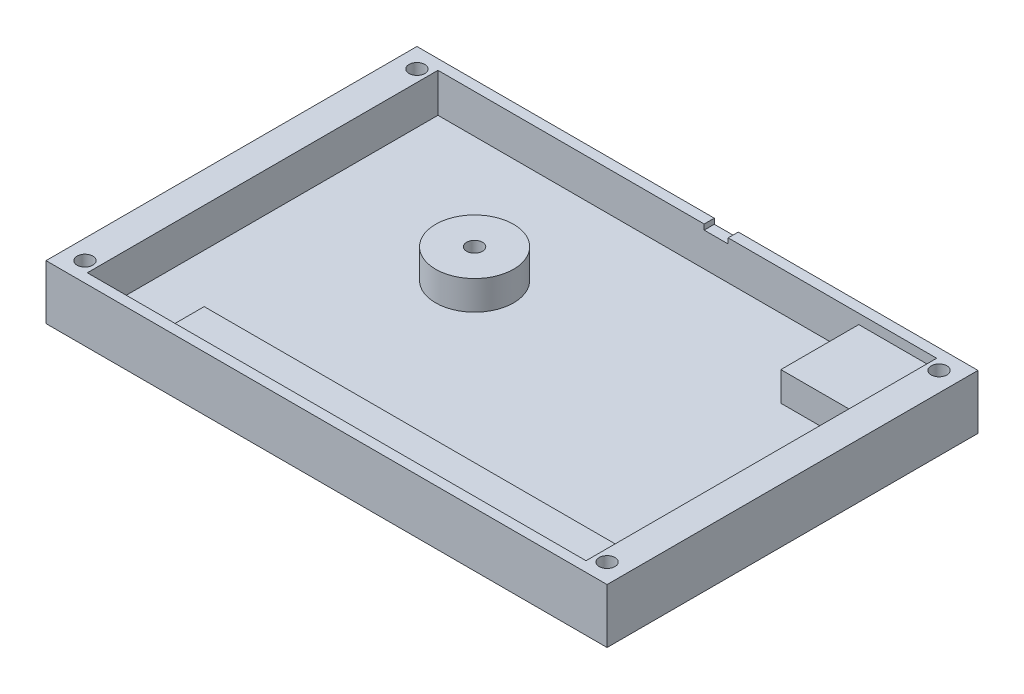
from build123d import *

# Parameters (mm, degrees)
SKETCH1_W           = 91.44
SKETCH1_H           = 60.452
BOSS_EXTRUDE1_DEPTH = 8.89
SKETCH2_W           = 81.28
SKETCH2_H           = 57.15
CUT_EXTRUDE1_DEPTH  = 1.6002
SKETCH3_R           = 6.35
SKETCH3_R_2         = 1.28905
CUT_EXTRUDE2_DEPTH  = 4.7498
SKETCH4_R           = 1.28905
CUT_EXTRUDE3_DEPTH  = 56.524423239
CUT_EXTRUDE4_REACH  = 78.314
SKETCH5_W           = 3.9116
SKETCH5_H           = 0.8636


with BuildPart() as part:
    # Sketch1 → Boss-Extrude1 (new body)
    with BuildSketch(Plane(origin=(0, 0, 0), x_dir=(1, 0, 0), z_dir=(0, 1, 0))):
        Rectangle(SKETCH1_W, SKETCH1_H)
    extrude(amount=BOSS_EXTRUDE1_DEPTH)

    # Sketch2 → Cut-Extrude1 (cut)
    with BuildSketch(Plane(origin=(0, 8.89, 0), x_dir=(1, 0, 0), z_dir=(0, 1, 0))):
        Rectangle(SKETCH2_W, SKETCH2_H)
    extrude(amount=-CUT_EXTRUDE1_DEPTH, mode=Mode.SUBTRACT)

    # Sketch3 → Cut-Extrude2 (cut)
    with BuildSketch(Plane(origin=(0, 7.2898, 0), x_dir=(1, 0, 0), z_dir=(0, 1, 0))):
        Polygon((-40.64, 28.575), (27.94, 28.575), (27.94, 15.875), (40.64, 15.875), (40.64, -22.225), (-27.94, -22.225), (-27.94, -28.575), (-40.64, -28.575), (-40.64, -22.225), align=None)
        with Locations(Location((-14.351, 8.255, 0), (0, 0, 270))):
            Circle(SKETCH3_R, mode=Mode.SUBTRACT)
        with Locations(Location((-14.351, 8.255, 0), (0, 0, 270))):
            Circle(SKETCH3_R_2)
    extrude(amount=-CUT_EXTRUDE2_DEPTH, mode=Mode.SUBTRACT)

    # Sketch4 → Cut-Extrude3 (cut, through all)
    with BuildSketch(Plane(origin=(0, 8.89, 0), x_dir=(1, 0, 0), z_dir=(0, 1, 0))):
        with Locations(Location((-42.545, 27.051, 0), (0, 0, 270))):
            Circle(SKETCH4_R)
        with Locations(Location((-42.545, -27.051, 0), (0, 0, 270))):
            Circle(SKETCH4_R)
        with Locations(Location((42.545, -27.051, 0), (0, 0, 270))):
            Circle(SKETCH4_R)
        with Locations(Location((42.545, 27.051, 0), (0, 0, 270))):
            Circle(SKETCH4_R)
    extrude(amount=-CUT_EXTRUDE3_DEPTH, mode=Mode.SUBTRACT)

    # Sketch5 → Cut-Extrude4 (cut, up to next)
    with BuildSketch(Plane(origin=(0, 0, -30.226), x_dir=(-1, 0, 0), z_dir=(0, 0, -1)), mode=Mode.PRIVATE) as cut_extrude4_sk1:
        with Locations((-4.699, 8.4582)):
            Rectangle(SKETCH5_W, SKETCH5_H)
    cut_extrude4_tool1 = extrude(cut_extrude4_sk1.sketch, amount=-CUT_EXTRUDE4_REACH, mode=Mode.PRIVATE) & part.part
    add(cut_extrude4_tool1.solids().sort_by_distance((4.699, 8.4582, -30.226))[0], mode=Mode.SUBTRACT)


solid = part.part
